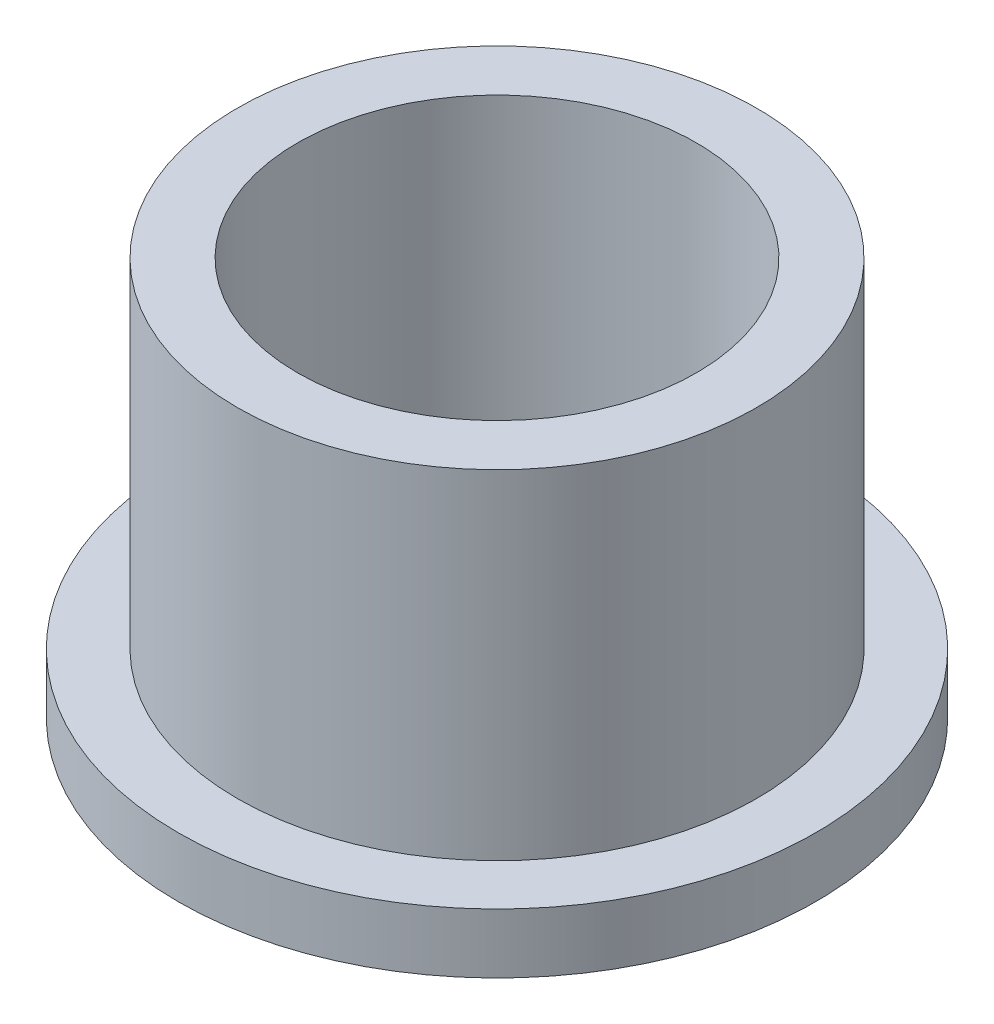
from build123d import *

# Parameters (mm, degrees)
SKETCH2_R           = 6.515
SKETCH2_R_2         = 5.005
BOSS_EXTRUDE1_DEPTH = 10
SKETCH3_R           = 8
SKETCH3_R_2         = 6.515
BOSS_EXTRUDE2_DEPTH = 1.5


with BuildPart() as part:
    # Sketch2 → Boss-Extrude1 (new body)
    with BuildSketch(Plane(origin=(0, 0, 0), x_dir=(1, 0, 0), z_dir=(0, 1, 0))):
        Circle(SKETCH2_R)
        Circle(SKETCH2_R_2, mode=Mode.SUBTRACT)
    extrude(amount=BOSS_EXTRUDE1_DEPTH)

    # Sketch3 → Boss-Extrude2 (add)
    with BuildSketch(Plane(origin=(0, 0, 0), x_dir=(1, 0, 0), z_dir=(0, 1, 0))):
        Circle(SKETCH3_R)
        Circle(SKETCH3_R_2, mode=Mode.SUBTRACT)
    extrude(amount=BOSS_EXTRUDE2_DEPTH)


solid = part.part
